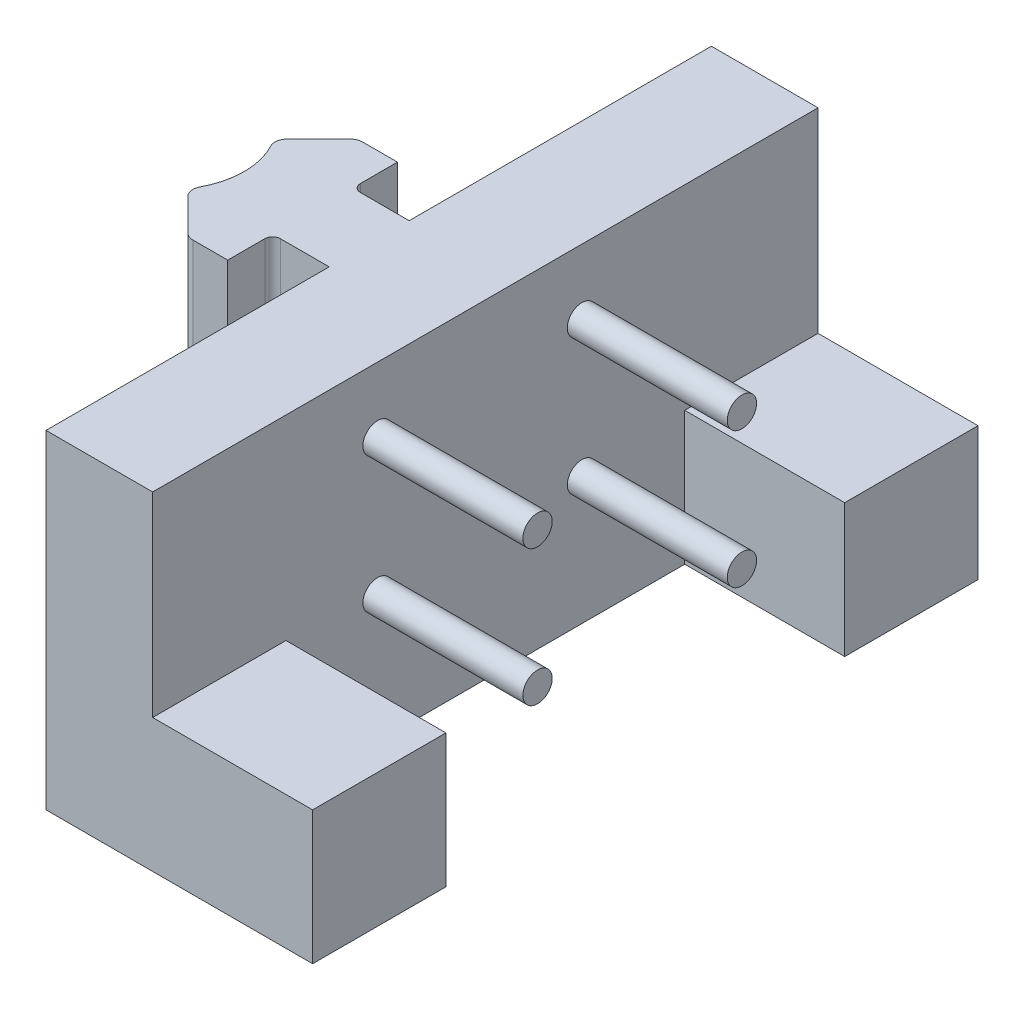
from build123d import *

# Parameters (mm, degrees)
SKETCH1_W           = 74.870479659
SKETCH1_H           = 36.98000569
BOSS_EXTRUDE1_DEPTH = 12
SKETCH3_R           = 1.651
BOSS_EXTRUDE2_DEPTH = 18
SKETCH4_W           = 15
SKETCH4_H           = 15
BOSS_EXTRUDE3_DEPTH = 18
SKETCH5_R           = 4.075
SKETCH5_R_2         = 4.25
CUT_EXTRUDE1_DEPTH  = 12
BOSS_EXTRUDE4_DEPTH = 36.980006


with BuildPart() as part:
    # Sketch1 → Boss-Extrude1 (new body)
    with BuildSketch(Plane.ZY.offset(-34.568450848)):
        with Locations((-283.368991002, -85.966002845)):
            Rectangle(SKETCH1_W, SKETCH1_H)
    extrude(amount=BOSS_EXTRUDE1_DEPTH)

    # Sketch3 → Boss-Extrude2 (add)
    with BuildSketch(Plane(origin=(34.568450848, 0, 0), x_dir=(0, 0, -1), z_dir=(1, 0, 0))):
        with Locations((271.241893694, -74.826)):
            Circle(SKETCH3_R)
        with Locations((271.241893694, -90.126)):
            Circle(SKETCH3_R)
        with Locations((294.241893694, -74.826)):
            Circle(SKETCH3_R)
        with Locations((294.241893694, -90.126)):
            Circle(SKETCH3_R)
    extrude(amount=BOSS_EXTRUDE2_DEPTH)

    # Sketch4 → Boss-Extrude3 (add)
    with BuildSketch(Plane(origin=(34.568450848, 0, 0), x_dir=(0, 0, -1), z_dir=(1, 0, 0))):
        with Locations((253.433751172, -96.95600569)):
            Rectangle(SKETCH4_W, SKETCH4_H)
        with Locations((313.304230831, -96.95600569)):
            Rectangle(SKETCH4_W, SKETCH4_H)
    extrude(amount=BOSS_EXTRUDE3_DEPTH)

    # Sketch5 → Cut-Extrude1 (cut)
    with BuildSketch(Plane.XZ.offset(104.45600569)):
        with Locations((45.518450848, -252.717)):
            Circle(SKETCH5_R)
        with Locations((45.518450848, -311.899)):
            Circle(SKETCH5_R_2)
    extrude(amount=-CUT_EXTRUDE1_DEPTH, mode=Mode.SUBTRACT)

    # Sketch7 → Boss-Extrude4 (add)
    with BuildSketch(Plane(origin=(0, -67.476, 0), x_dir=(1, 0, 0), z_dir=(0, 1, 0))):
        with BuildLine():
            Line((8.49017791, 282.708508335), (8.49017791, 281.891491665))
            ThreePointArc((8.49017791, 281.891491665), (8.198108508, 280.0547791), (7.513571814, 278.325551788))
            ThreePointArc((7.513571814, 278.325551788), (7.368274769, 277.471769831), (7.758499153, 276.698607628))
            Line((7.758499153, 276.698607628), (11.301449673, 273.155657108))
            ThreePointArc((11.301449673, 273.155657108), (11.750776011, 272.855426847), (12.280792565, 272.75))
            Line((12.280792565, 272.75), (16.2, 272.75))
            Line((16.2, 272.75), (16.2, 276.923))
            ThreePointArc((16.2, 276.923), (16.456867353, 277.543132647), (17.077, 277.8))
            Line((17.077, 277.8), (20.8615, 277.8))
            Line((20.8615, 277.8), (22.568450848, 277.8))
            Line((22.568450848, 277.8), (22.568450848, 286.8))
            Line((22.568450848, 286.8), (20.8615, 286.8))
            Line((20.8615, 286.8), (17.077, 286.8))
            ThreePointArc((17.077, 286.8), (16.456867353, 287.056867353), (16.2, 287.677))
            Line((16.2, 287.677), (16.2, 291.85))
            Line((16.2, 291.85), (12.280792565, 291.85))
            ThreePointArc((12.280792565, 291.85), (11.750776011, 291.744573153), (11.301449673, 291.444342892))
            Line((11.301449673, 291.444342892), (7.758499153, 287.901392372))
            ThreePointArc((7.758499153, 287.901392372), (7.368274769, 287.128230169), (7.513571814, 286.274448212))
            ThreePointArc((7.513571814, 286.274448212), (8.198108508, 284.5452209), (8.49017791, 282.708508335))
        make_face()
    extrude(amount=-BOSS_EXTRUDE4_DEPTH)


solid = part.part
